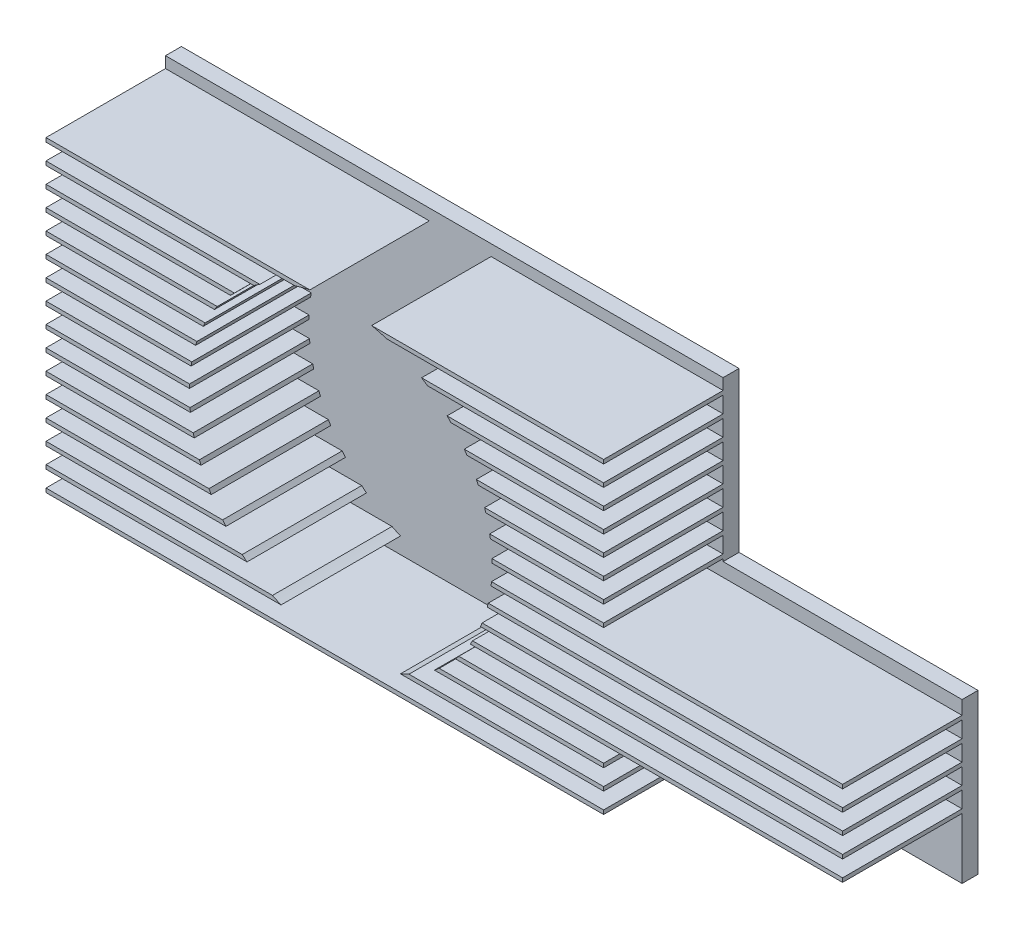
from build123d import *

# Parameters (mm, degrees)
MAIN_SKETCH_W              = 100
MAIN_SKETCH_H              = 40
MAIN_DEPTH                 = 2
ESQUISSE2_W                = 100
ESQUISSE2_H                = 0.5
BOSS_EXTRU_2_DEPTH         = 15
R_P_TITION_LIN_AIRE2_COUNT = 16
R_P_TITION_LIN_AIRE2_PITCH = 2.54
ESQUISSE3_W                = 30
ESQUISSE3_H                = 7.5
ENL_V_MAT_EXTRU_1_DEPTH    = 16
ESQUISSE4_W                = 30
ESQUISSE4_H                = 20
ENL_V_MAT_EXTRU_2_DEPTH    = 25
ESQUISSE5_R                = 19
ENL_V_MAT_EXTRU_3_DEPTH    = 16


with BuildPart() as part:
    # Main-Sketch → Main (new body)
    with BuildSketch(Plane.XY):
        with Locations((50, 20)):
            Rectangle(MAIN_SKETCH_W, MAIN_SKETCH_H)
    extrude(amount=MAIN_DEPTH)

    # Esquisse2 → Boss.-Extru.2 (add)
    with BuildSketch(Plane.XY.offset(2)):
        with Locations((50, 0.25)):
            Rectangle(ESQUISSE2_W, ESQUISSE2_H)
    boss_extru_2 = extrude(amount=BOSS_EXTRU_2_DEPTH)

    # Répétition linéaire2: Boss.-Extru.2 ×16
    with Locations(*[(0, i * R_P_TITION_LIN_AIRE2_PITCH, 0) for i in range(1, R_P_TITION_LIN_AIRE2_COUNT)]):
        add(boss_extru_2)

    # Esquisse3 → Enlèv. mat.-Extru.1 (cut, through all)
    with BuildSketch(Plane.XY.offset(2)):
        with Locations((85, 3.75)):
            Rectangle(ESQUISSE3_W, ESQUISSE3_H)
    extrude(amount=ENL_V_MAT_EXTRU_1_DEPTH, mode=Mode.SUBTRACT)

    # Esquisse4 → Enlèv. mat.-Extru.2 (cut, symmetric)
    with BuildSketch(Plane.XY.offset(2)):
        with Locations((85, 30)):
            Rectangle(ESQUISSE4_W, ESQUISSE4_H)
    extrude(amount=ENL_V_MAT_EXTRU_2_DEPTH, both=True, mode=Mode.SUBTRACT)

    # Esquisse5 → Enlèv. mat.-Extru.3 (cut, through all)
    with BuildSketch(Plane.XY.offset(2)):
        with Locations((37, 20)):
            Circle(ESQUISSE5_R)
    extrude(amount=ENL_V_MAT_EXTRU_3_DEPTH, mode=Mode.SUBTRACT)


solid = part.part
